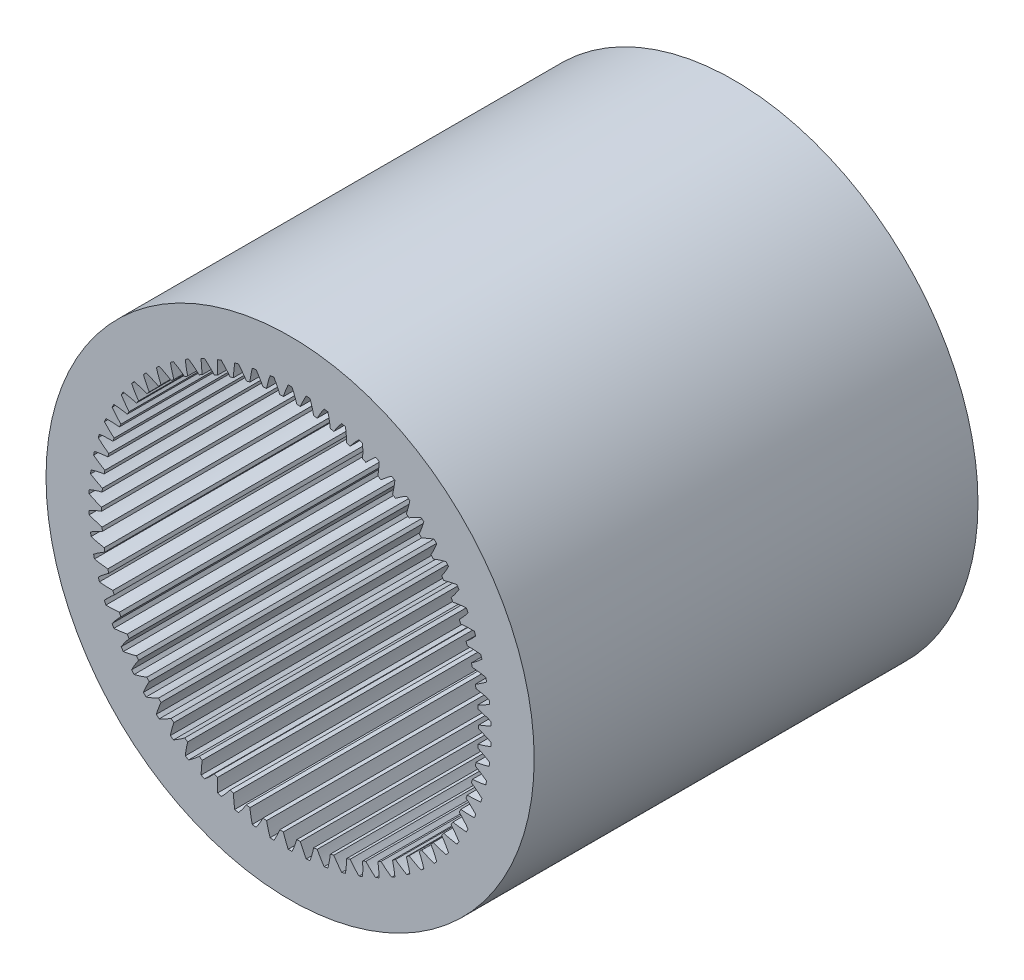
from build123d import *

# Parameters (mm, degrees)
SKETCH1_R           = 11
BOSS_EXTRUDE1_DEPTH = 20


with BuildPart() as part:
    # Sketch1 → Boss-Extrude1 (new body)
    with BuildSketch(Plane.XY):
        Circle(SKETCH1_R)
        with BuildLine():
            ThreePointArc((-8.348650628, -1.596882177), (-8.607630644, -1.756276652), (-8.854912419, -1.933276571))
            ThreePointArc((-8.854912419, -1.933276571), (-8.836259132, -2.016818485), (-8.816817685, -2.100180506))
            ThreePointArc((-8.816817685, -2.100180506), (-8.517227118, -2.152360382), (-8.214735515, -2.183602624))
            ThreePointArc((-8.214735515, -2.183602624), (-8.193684316, -2.261313187), (-8.171898, -2.338820872))
            ThreePointArc((-8.171898, -2.338820872), (-8.415547429, -2.520788461), (-8.645967569, -2.719241998))
            ThreePointArc((-8.645967569, -2.719241998), (-8.619900735, -2.800775529), (-8.59306504, -2.882059241))
            ThreePointArc((-8.59306504, -2.882059241), (-8.290003168, -2.907173964), (-7.985928775, -2.911175296))
            ThreePointArc((-7.985928775, -2.911175296), (-7.9579964, -2.986686005), (-7.929350055, -3.061928756))
            ThreePointArc((-7.929350055, -3.061928756), (-8.155707173, -3.265004363), (-8.367410472, -3.483313687))
            ThreePointArc((-8.367410472, -3.483313687), (-8.334139967, -3.562182374), (-8.300126088, -3.640733329))
            ThreePointArc((-8.300126088, -3.640733329), (-7.996032988, -3.638580692), (-7.692824032, -3.615308896))
            ThreePointArc((-7.692824032, -3.615308896), (-7.658235377, -3.688011782), (-7.622959645, -3.76038379))
            ThreePointArc((-7.622959645, -3.76038379), (-7.830201959, -3.98293237), (-8.021483906, -4.219339782))
            ThreePointArc((-8.021483906, -4.219339782), (-7.981277603, -4.294908622), (-7.940359401, -4.370094374))
            ThreePointArc((-7.940359401, -4.370094374), (-7.637683451, -4.340691706), (-7.337781193, -4.290334155))
            ThreePointArc((-7.337781193, -4.290334155), (-7.296814746, -4.359643858), (-7.255193647, -4.428562424))
            ThreePointArc((-7.255193647, -4.428562424), (-7.441652563, -4.668792148), (-7.610973068, -4.921394234))
            ThreePointArc((-7.610973068, -4.921394234), (-7.564154685, -4.993054791), (-7.516661609, -5.064269988))
            ThreePointArc((-7.516661609, -5.064269988), (-7.217839778, -5.007854024), (-6.923658854, -4.930816166))
            ThreePointArc((-6.923658854, -4.930816166), (-6.876644452, -4.996174644), (-6.829013095, -5.061084879))
            ThreePointArc((-6.829013095, -5.061084879), (-6.993187356, -5.317061556), (-7.13918315, -5.583824514))
            ThreePointArc((-7.13918315, -5.583824514), (-7.086129641, -5.650999819), (-7.032444077, -5.717671077))
            ThreePointArc((-7.032444077, -5.717671077), (-6.739882304, -5.634696045), (-6.453791286, -5.531598145))
            ThreePointArc((-6.453791286, -5.531598145), (-6.401107461, -5.59247917), (-6.347849345, -5.652858453))
            ThreePointArc((-6.347849345, -5.652858453), (-6.488417117, -5.922521111), (-6.609912727, -6.201297121))
            ThreePointArc((-6.609912727, -6.201297121), (-6.551051248, -6.263446319), (-6.491605441, -6.325036842))
            ThreePointArc((-6.491605441, -6.325036842), (-6.207659259, -6.216170808), (-5.931961585, -6.087842948))
            ThreePointArc((-5.931961585, -6.087842948), (-5.874032516, -6.143756343), (-5.815576445, -6.199118535))
            ThreePointArc((-5.815576445, -6.199118535), (-5.931405958, -6.480296008), (-6.027423174, -6.768840531))
            ThreePointArc((-6.027423174, -6.768840531), (-5.963227643, -6.825463232), (-5.898500215, -6.881477128))
            ThreePointArc((-5.898500215, -6.881477128), (-5.625455793, -6.747596617), (-5.362371217, -6.595072019))
            ThreePointArc((-5.362371217, -6.595072019), (-5.299663316, -6.645567601), (-5.236479943, -6.69546696))
            ThreePointArc((-5.236479943, -6.69546696), (-5.326638605, -6.985895373), (-5.396404353, -7.281885217))
            ThreePointArc((-5.396404353, -7.281885217), (-5.327391634, -7.332525529), (-5.257903733, -7.382511807))
            ThreePointArc((-5.257903733, -7.382511807), (-4.997959464, -7.224694747), (-4.749606189, -7.049201448))
            ThreePointArc((-4.749606189, -7.049201448), (-4.682624342, -7.093872657), (-4.615222383, -7.137907422))
            ThreePointArc((-4.615222383, -7.137907422), (-4.678984291, -7.435248415), (-4.721936857, -7.736300445))
            ThreePointArc((-4.721936857, -7.736300445), (-4.648662601, -7.780550641), (-4.574973702, -7.824106842))
            ThreePointArc((-4.574973702, -7.824106842), (-4.330222505, -7.643623882), (-4.098600125, -7.446574851))
            ThreePointArc((-4.098600125, -7.446574851), (-4.027883631, -7.485062021), (-3.956805766, -7.52287765))
            ThreePointArc((-3.956805766, -7.52287765), (-3.993657546, -7.824737209), (-4.009451102, -8.12842753))
            ThreePointArc((-4.009451102, -8.12842753), (-3.932505269, -8.165931334), (-3.855208673, -8.202706769))
            ThreePointArc((-3.855208673, -8.202706769), (-3.62762114, -8.001011052), (-3.414594542, -7.783992813))
            ThreePointArc((-3.414594542, -7.783992813), (-3.340712769, -7.815986067), (-3.266531276, -7.84727809))
            ThreePointArc((-3.266531276, -7.84727809), (-3.276176219, -8.15122582), (-3.264683604, -8.455109296))
            ThreePointArc((-3.264683604, -8.455109296), (-3.184685718, -8.48556475), (-3.10440377, -8.515263324))
            ThreePointArc((-3.10440377, -8.515263324), (-2.895812302, -8.293978786), (-2.703096652, -8.058738641))
            ThreePointArc((-2.703096652, -8.058738641), (-2.626644452, -8.083980389), (-2.549956596, -8.108496862))
            ThreePointArc((-2.549956596, -8.108496862), (-2.532317048, -8.412085553), (-2.493630794, -8.713715494))
            ThreePointArc((-2.493630794, -8.713715494), (-2.41122495, -8.736877388), (-2.328604034, -8.759259986))
            ThreePointArc((-2.328604034, -8.759259986), (-2.140688087, -8.520168279), (-1.969835017, -8.268600245))
            ThreePointArc((-1.969835017, -8.268600245), (-1.891427939, -8.286887254), (-1.812851166, -8.304430784))
            ThreePointArc((-1.812851166, -8.304430784), (-1.768069149, -8.60521612), (-1.702500735, -8.902163978))
            ThreePointArc((-1.702500735, -8.902163978), (-1.618350416, -8.917845826), (-1.534055747, -8.932732237))
            ThreePointArc((-1.534055747, -8.932732237), (-1.36832831, -8.677758387), (-1.220713429, -8.411887941))
            ThreePointArc((-1.220713429, -8.411887941), (-1.140982759, -8.423072975), (-1.061149724, -8.433502313))
            ThreePointArc((-1.061149724, -8.433502313), (-0.989585796, -8.729062547), (-0.89766314, -9.018937473))
            ThreePointArc((-0.89766314, -9.018937473), (-0.812445876, -9.027013014), (-0.727156145, -9.03428338))
            ThreePointArc((-0.727156145, -9.03428338), (-0.584951558, -8.765480287), (-0.461763374, -8.487448061))
            ThreePointArc((-0.461763374, -8.487448061), (-0.381351058, -8.491441066), (-0.300904528, -8.49467224))
            ThreePointArc((-0.300904528, -8.49467224), (-0.20313488, -8.782627694), (-0.08559809, -9.063095785))
            ThreePointArc((-0.08559809, -9.063095785), (0, -9.0635), (0.08559809, -9.063095785))
            ThreePointArc((0.08559809, -9.063095785), (0.20313488, -8.782627694), (0.300904528, -8.49467224))
            ThreePointArc((0.300904528, -8.49467224), (0.381351058, -8.491441066), (0.461763374, -8.487448061))
            ThreePointArc((0.461763374, -8.487448061), (0.584951558, -8.765480287), (0.727156145, -9.03428338))
            ThreePointArc((0.727156145, -9.03428338), (0.812445876, -9.027013014), (0.89766314, -9.018937473))
            ThreePointArc((0.89766314, -9.018937473), (0.989585796, -8.729062547), (1.061149724, -8.433502313))
            ThreePointArc((1.061149724, -8.433502313), (1.140982759, -8.423072975), (1.220713429, -8.411887941))
            ThreePointArc((1.220713429, -8.411887941), (1.36832831, -8.677758387), (1.534055747, -8.932732237))
            ThreePointArc((1.534055747, -8.932732237), (1.618350416, -8.917845826), (1.702500735, -8.902163978))
            ThreePointArc((1.702500735, -8.902163978), (1.768069149, -8.60521612), (1.812851166, -8.304430784))
            ThreePointArc((1.812851166, -8.304430784), (1.891427939, -8.286887254), (1.969835017, -8.268600245))
            ThreePointArc((1.969835017, -8.268600245), (2.140688087, -8.520168279), (2.328604034, -8.759259986))
            ThreePointArc((2.328604034, -8.759259986), (2.41122495, -8.736877388), (2.493630794, -8.713715494))
            ThreePointArc((2.493630794, -8.713715494), (2.532317048, -8.412085553), (2.549956596, -8.108496862))
            ThreePointArc((2.549956596, -8.108496862), (2.626644452, -8.083980389), (2.703096652, -8.058738641))
            ThreePointArc((2.703096652, -8.058738641), (2.895812302, -8.293978786), (3.10440377, -8.515263324))
            ThreePointArc((3.10440377, -8.515263324), (3.184685718, -8.48556475), (3.264683604, -8.455109296))
            ThreePointArc((3.264683604, -8.455109296), (3.276176219, -8.15122582), (3.266531276, -7.84727809))
            ThreePointArc((3.266531276, -7.84727809), (3.340712769, -7.815986067), (3.414594542, -7.783992813))
            ThreePointArc((3.414594542, -7.783992813), (3.62762114, -8.001011052), (3.855208673, -8.202706769))
            ThreePointArc((3.855208673, -8.202706769), (3.932505269, -8.165931334), (4.009451102, -8.12842753))
            ThreePointArc((4.009451102, -8.12842753), (3.993657546, -7.824737209), (3.956805766, -7.52287765))
            ThreePointArc((3.956805766, -7.52287765), (4.027883631, -7.485062021), (4.098600125, -7.446574851))
            ThreePointArc((4.098600125, -7.446574851), (4.330222505, -7.643623882), (4.574973702, -7.824106842))
            ThreePointArc((4.574973702, -7.824106842), (4.648662601, -7.780550641), (4.721936857, -7.736300445))
            ThreePointArc((4.721936857, -7.736300445), (4.678984291, -7.435248415), (4.615222383, -7.137907422))
            ThreePointArc((4.615222383, -7.137907422), (4.682624342, -7.093872657), (4.749606189, -7.049201448))
            ThreePointArc((4.749606189, -7.049201448), (4.997959464, -7.224694747), (5.257903733, -7.382511807))
            ThreePointArc((5.257903733, -7.382511807), (5.327391634, -7.332525529), (5.396404353, -7.281885217))
            ThreePointArc((5.396404353, -7.281885217), (5.326638605, -6.985895373), (5.236479943, -6.69546696))
            ThreePointArc((5.236479943, -6.69546696), (5.299663316, -6.645567601), (5.362371217, -6.595072019))
            ThreePointArc((5.362371217, -6.595072019), (5.625455793, -6.747596617), (5.898500215, -6.881477128))
            ThreePointArc((5.898500215, -6.881477128), (5.963227643, -6.825463232), (6.027423174, -6.768840531))
            ThreePointArc((6.027423174, -6.768840531), (5.931405958, -6.480296008), (5.815576445, -6.199118535))
            ThreePointArc((5.815576445, -6.199118535), (5.874032516, -6.143756343), (5.931961585, -6.087842948))
            ThreePointArc((5.931961585, -6.087842948), (6.207659259, -6.216170808), (6.491605441, -6.325036842))
            ThreePointArc((6.491605441, -6.325036842), (6.551051248, -6.263446319), (6.609912727, -6.201297121))
            ThreePointArc((6.609912727, -6.201297121), (6.488417117, -5.922521111), (6.347849345, -5.652858453))
            ThreePointArc((6.347849345, -5.652858453), (6.401107461, -5.59247917), (6.453791286, -5.531598145))
            ThreePointArc((6.453791286, -5.531598145), (6.739882304, -5.634696045), (7.032444077, -5.717671077))
            ThreePointArc((7.032444077, -5.717671077), (7.086129641, -5.650999819), (7.13918315, -5.583824514))
            ThreePointArc((7.13918315, -5.583824514), (6.993187356, -5.317061556), (6.829013095, -5.061084879))
            ThreePointArc((6.829013095, -5.061084879), (6.876644452, -4.996174644), (6.923658854, -4.930816166))
            ThreePointArc((6.923658854, -4.930816166), (7.217839778, -5.007854024), (7.516661609, -5.064269988))
            ThreePointArc((7.516661609, -5.064269988), (7.564154685, -4.993054791), (7.610973068, -4.921394234))
            ThreePointArc((7.610973068, -4.921394234), (7.441652563, -4.668792148), (7.255193647, -4.428562424))
            ThreePointArc((7.255193647, -4.428562424), (7.296814746, -4.359643858), (7.337781193, -4.290334155))
            ThreePointArc((7.337781193, -4.290334155), (7.637683451, -4.340691706), (7.940359401, -4.370094374))
            ThreePointArc((7.940359401, -4.370094374), (7.981277603, -4.294908622), (8.021483906, -4.219339782))
            ThreePointArc((8.021483906, -4.219339782), (7.830201959, -3.98293237), (7.622959645, -3.76038379))
            ThreePointArc((7.622959645, -3.76038379), (7.658235377, -3.688011782), (7.692824032, -3.615308896))
            ThreePointArc((7.692824032, -3.615308896), (7.996032988, -3.638580692), (8.300126088, -3.640733329))
            ThreePointArc((8.300126088, -3.640733329), (8.334139967, -3.562182374), (8.367410472, -3.483313687))
            ThreePointArc((8.367410472, -3.483313687), (8.155707173, -3.265004363), (7.929350055, -3.061928756))
            ThreePointArc((7.929350055, -3.061928756), (7.9579964, -2.986686005), (7.985928775, -2.911175296))
            ThreePointArc((7.985928775, -2.911175296), (8.290003168, -2.907173964), (8.59306504, -2.882059241))
            ThreePointArc((8.59306504, -2.882059241), (8.619900735, -2.800775529), (8.645967569, -2.719241998))
            ThreePointArc((8.645967569, -2.719241998), (8.415547429, -2.520788461), (8.171898, -2.338820872))
            ThreePointArc((8.171898, -2.338820872), (8.193684316, -2.261313187), (8.214735515, -2.183602624))
            ThreePointArc((8.214735515, -2.183602624), (8.517227118, -2.152360382), (8.816817685, -2.100180506))
            ThreePointArc((8.816817685, -2.100180506), (8.836259132, -2.016818485), (8.854912419, -1.933276571))
            ThreePointArc((8.854912419, -1.933276571), (8.607630644, -1.756276652), (8.348650628, -1.596882177))
            ThreePointArc((8.348650628, -1.596882177), (8.363401503, -1.517733606), (8.377402035, -1.438448867))
            ThreePointArc((8.377402035, -1.438448867), (8.675875363, -1.380217259), (8.969582498, -1.301392353))
            ThreePointArc((8.969582498, -1.301392353), (8.981473166, -1.216623205), (8.992562721, -1.131745538))
            ThreePointArc((8.992562721, -1.131745538), (8.730410279, -0.977624336), (8.45818483, -0.842086327))
            ThreePointArc((8.45818483, -0.842086327), (8.465781499, -0.761934126), (8.47261864, -0.681713566))
            ThreePointArc((8.47261864, -0.681713566), (8.76467056, -0.596961439), (9.050129507, -0.492126154))
            ThreePointArc((9.050129507, -0.492126154), (9.054373659, -0.40663239), (9.057810195, -0.321102356))
            ThreePointArc((9.057810195, -0.321102356), (8.782897784, -0.191100764), (8.499618701, -0.080510492))
            ThreePointArc((8.499618701, -0.080510492), (8.5, 0), (8.499618701, 0.080510492))
            ThreePointArc((8.499618701, 0.080510492), (8.782897784, 0.191100764), (9.057810195, 0.321102356))
            ThreePointArc((9.057810195, 0.321102356), (9.054373659, 0.40663239), (9.050129507, 0.492126154))
            ThreePointArc((9.050129507, 0.492126154), (8.76467056, 0.596961439), (8.47261864, 0.681713566))
            ThreePointArc((8.47261864, 0.681713566), (8.465781499, 0.761934126), (8.45818483, 0.842086327))
            ThreePointArc((8.45818483, 0.842086327), (8.730410279, 0.977624336), (8.992562721, 1.131745538))
            ThreePointArc((8.992562721, 1.131745538), (8.981473166, 1.216623205), (8.969582498, 1.301392353))
            ThreePointArc((8.969582498, 1.301392353), (8.675875363, 1.380217259), (8.377402035, 1.438448867))
            ThreePointArc((8.377402035, 1.438448867), (8.363401503, 1.517733606), (8.348650628, 1.596882177))
            ThreePointArc((8.348650628, 1.596882177), (8.607630644, 1.756276652), (8.854912419, 1.933276571))
            ThreePointArc((8.854912419, 1.933276571), (8.836259132, 2.016818485), (8.816817685, 2.100180506))
            ThreePointArc((8.816817685, 2.100180506), (8.517227118, 2.152360382), (8.214735515, 2.183602624))
            ThreePointArc((8.214735515, 2.183602624), (8.193684316, 2.261313187), (8.171898, 2.338820872))
            ThreePointArc((8.171898, 2.338820872), (8.415547429, 2.520788461), (8.645967569, 2.719241998))
            ThreePointArc((8.645967569, 2.719241998), (8.619900735, 2.800775529), (8.59306504, 2.882059241))
            ThreePointArc((8.59306504, 2.882059241), (8.290003168, 2.907173964), (7.985928775, 2.911175296))
            ThreePointArc((7.985928775, 2.911175296), (7.9579964, 2.986686005), (7.929350055, 3.061928756))
            ThreePointArc((7.929350055, 3.061928756), (8.155707173, 3.265004363), (8.367410472, 3.483313687))
            ThreePointArc((8.367410472, 3.483313687), (8.334139967, 3.562182374), (8.300126088, 3.640733329))
            ThreePointArc((8.300126088, 3.640733329), (7.996032988, 3.638580692), (7.692824032, 3.615308896))
            ThreePointArc((7.692824032, 3.615308896), (7.658235377, 3.688011782), (7.622959645, 3.76038379))
            ThreePointArc((7.622959645, 3.76038379), (7.830201959, 3.98293237), (8.021483906, 4.219339782))
            ThreePointArc((8.021483906, 4.219339782), (7.981277603, 4.294908622), (7.940359401, 4.370094374))
            ThreePointArc((7.940359401, 4.370094374), (7.637683451, 4.340691706), (7.337781193, 4.290334155))
            ThreePointArc((7.337781193, 4.290334155), (7.296814746, 4.359643858), (7.255193647, 4.428562424))
            ThreePointArc((7.255193647, 4.428562424), (7.441652563, 4.668792148), (7.610973068, 4.921394234))
            ThreePointArc((7.610973068, 4.921394234), (7.564154685, 4.993054791), (7.516661609, 5.064269988))
            ThreePointArc((7.516661609, 5.064269988), (7.217839778, 5.007854024), (6.923658854, 4.930816166))
            ThreePointArc((6.923658854, 4.930816166), (6.876644452, 4.996174644), (6.829013095, 5.061084879))
            ThreePointArc((6.829013095, 5.061084879), (6.993187356, 5.317061556), (7.13918315, 5.583824514))
            ThreePointArc((7.13918315, 5.583824514), (7.086129641, 5.650999819), (7.032444077, 5.717671077))
            ThreePointArc((7.032444077, 5.717671077), (6.739882304, 5.634696045), (6.453791286, 5.531598145))
            ThreePointArc((6.453791286, 5.531598145), (6.401107461, 5.59247917), (6.347849345, 5.652858453))
            ThreePointArc((6.347849345, 5.652858453), (6.488417117, 5.922521111), (6.609912727, 6.201297121))
            ThreePointArc((6.609912727, 6.201297121), (6.551051248, 6.263446319), (6.491605441, 6.325036842))
            ThreePointArc((6.491605441, 6.325036842), (6.207659259, 6.216170808), (5.931961585, 6.087842948))
            ThreePointArc((5.931961585, 6.087842948), (5.874032516, 6.143756343), (5.815576445, 6.199118535))
            ThreePointArc((5.815576445, 6.199118535), (5.931405958, 6.480296008), (6.027423174, 6.768840531))
            ThreePointArc((6.027423174, 6.768840531), (5.963227643, 6.825463232), (5.898500215, 6.881477128))
            ThreePointArc((5.898500215, 6.881477128), (5.625455793, 6.747596617), (5.362371217, 6.595072019))
            ThreePointArc((5.362371217, 6.595072019), (5.299663316, 6.645567601), (5.236479943, 6.69546696))
            ThreePointArc((5.236479943, 6.69546696), (5.326638605, 6.985895373), (5.396404353, 7.281885217))
            ThreePointArc((5.396404353, 7.281885217), (5.327391634, 7.332525529), (5.257903733, 7.382511807))
            ThreePointArc((5.257903733, 7.382511807), (4.997959464, 7.224694747), (4.749606189, 7.049201448))
            ThreePointArc((4.749606189, 7.049201448), (4.682624342, 7.093872657), (4.615222383, 7.137907422))
            ThreePointArc((4.615222383, 7.137907422), (4.678984291, 7.435248415), (4.721936857, 7.736300445))
            ThreePointArc((4.721936857, 7.736300445), (4.648662601, 7.780550641), (4.574973702, 7.824106842))
            ThreePointArc((4.574973702, 7.824106842), (4.330222505, 7.643623882), (4.098600125, 7.446574851))
            ThreePointArc((4.098600125, 7.446574851), (4.027883631, 7.485062021), (3.956805766, 7.52287765))
            ThreePointArc((3.956805766, 7.52287765), (3.993657546, 7.824737209), (4.009451102, 8.12842753))
            ThreePointArc((4.009451102, 8.12842753), (3.932505269, 8.165931334), (3.855208673, 8.202706769))
            ThreePointArc((3.855208673, 8.202706769), (3.62762114, 8.001011052), (3.414594542, 7.783992813))
            ThreePointArc((3.414594542, 7.783992813), (3.340712769, 7.815986067), (3.266531276, 7.84727809))
            ThreePointArc((3.266531276, 7.84727809), (3.276176219, 8.15122582), (3.264683604, 8.455109296))
            ThreePointArc((3.264683604, 8.455109296), (3.184685718, 8.48556475), (3.10440377, 8.515263324))
            ThreePointArc((3.10440377, 8.515263324), (2.895812302, 8.293978786), (2.703096652, 8.058738641))
            ThreePointArc((2.703096652, 8.058738641), (2.626644452, 8.083980389), (2.549956596, 8.108496862))
            ThreePointArc((2.549956596, 8.108496862), (2.532317048, 8.412085553), (2.493630794, 8.713715494))
            ThreePointArc((2.493630794, 8.713715494), (2.41122495, 8.736877388), (2.328604034, 8.759259986))
            ThreePointArc((2.328604034, 8.759259986), (2.140688087, 8.520168279), (1.969835017, 8.268600245))
            ThreePointArc((1.969835017, 8.268600245), (1.891427939, 8.286887254), (1.812851166, 8.304430784))
            ThreePointArc((1.812851166, 8.304430784), (1.768069149, 8.60521612), (1.702500735, 8.902163978))
            ThreePointArc((1.702500735, 8.902163978), (1.618350416, 8.917845826), (1.534055747, 8.932732237))
            ThreePointArc((1.534055747, 8.932732237), (1.36832831, 8.677758387), (1.220713429, 8.411887941))
            ThreePointArc((1.220713429, 8.411887941), (1.140982759, 8.423072975), (1.061149724, 8.433502313))
            ThreePointArc((1.061149724, 8.433502313), (0.989585796, 8.729062547), (0.89766314, 9.018937473))
            ThreePointArc((0.89766314, 9.018937473), (0.812445876, 9.027013014), (0.727156145, 9.03428338))
            ThreePointArc((0.727156145, 9.03428338), (0.584951558, 8.765480287), (0.461763374, 8.487448061))
            ThreePointArc((0.461763374, 8.487448061), (0.381351058, 8.491441066), (0.300904528, 8.49467224))
            ThreePointArc((0.300904528, 8.49467224), (0.20313488, 8.782627694), (0.08559809, 9.063095785))
            ThreePointArc((0.08559809, 9.063095785), (0, 9.0635), (-0.08559809, 9.063095785))
            ThreePointArc((-0.08559809, 9.063095785), (-0.20313488, 8.782627694), (-0.300904528, 8.49467224))
            ThreePointArc((-0.300904528, 8.49467224), (-0.381351058, 8.491441066), (-0.461763374, 8.487448061))
            ThreePointArc((-0.461763374, 8.487448061), (-0.584951558, 8.765480287), (-0.727156145, 9.03428338))
            ThreePointArc((-0.727156145, 9.03428338), (-0.812445876, 9.027013014), (-0.89766314, 9.018937473))
            ThreePointArc((-0.89766314, 9.018937473), (-0.989585796, 8.729062547), (-1.061149724, 8.433502313))
            ThreePointArc((-1.061149724, 8.433502313), (-1.140982759, 8.423072975), (-1.220713429, 8.411887941))
            ThreePointArc((-1.220713429, 8.411887941), (-1.36832831, 8.677758387), (-1.534055747, 8.932732237))
            ThreePointArc((-1.534055747, 8.932732237), (-1.618350416, 8.917845826), (-1.702500735, 8.902163978))
            ThreePointArc((-1.702500735, 8.902163978), (-1.768069149, 8.60521612), (-1.812851166, 8.304430784))
            ThreePointArc((-1.812851166, 8.304430784), (-1.891427939, 8.286887254), (-1.969835017, 8.268600245))
            ThreePointArc((-1.969835017, 8.268600245), (-2.140688087, 8.520168279), (-2.328604034, 8.759259986))
            ThreePointArc((-2.328604034, 8.759259986), (-2.41122495, 8.736877388), (-2.493630794, 8.713715494))
            ThreePointArc((-2.493630794, 8.713715494), (-2.532317048, 8.412085553), (-2.549956596, 8.108496862))
            ThreePointArc((-2.549956596, 8.108496862), (-2.626644452, 8.083980389), (-2.703096652, 8.058738641))
            ThreePointArc((-2.703096652, 8.058738641), (-2.895812302, 8.293978786), (-3.10440377, 8.515263324))
            ThreePointArc((-3.10440377, 8.515263324), (-3.184685718, 8.48556475), (-3.264683604, 8.455109296))
            ThreePointArc((-3.264683604, 8.455109296), (-3.276176219, 8.15122582), (-3.266531276, 7.84727809))
            ThreePointArc((-3.266531276, 7.84727809), (-3.340712769, 7.815986067), (-3.414594542, 7.783992813))
            ThreePointArc((-3.414594542, 7.783992813), (-3.62762114, 8.001011052), (-3.855208673, 8.202706769))
            ThreePointArc((-3.855208673, 8.202706769), (-3.932505269, 8.165931334), (-4.009451102, 8.12842753))
            ThreePointArc((-4.009451102, 8.12842753), (-3.993657546, 7.824737209), (-3.956805766, 7.52287765))
            ThreePointArc((-3.956805766, 7.52287765), (-4.027883631, 7.485062021), (-4.098600125, 7.446574851))
            ThreePointArc((-4.098600125, 7.446574851), (-4.330222505, 7.643623882), (-4.574973702, 7.824106842))
            ThreePointArc((-4.574973702, 7.824106842), (-4.648662601, 7.780550641), (-4.721936857, 7.736300445))
            ThreePointArc((-4.721936857, 7.736300445), (-4.678984291, 7.435248415), (-4.615222383, 7.137907422))
            ThreePointArc((-4.615222383, 7.137907422), (-4.682624342, 7.093872657), (-4.749606189, 7.049201448))
            ThreePointArc((-4.749606189, 7.049201448), (-4.997959464, 7.224694747), (-5.257903733, 7.382511807))
            ThreePointArc((-5.257903733, 7.382511807), (-5.327391634, 7.332525529), (-5.396404353, 7.281885217))
            ThreePointArc((-5.396404353, 7.281885217), (-5.326638605, 6.985895373), (-5.236479943, 6.69546696))
            ThreePointArc((-5.236479943, 6.69546696), (-5.299663316, 6.645567601), (-5.362371217, 6.595072019))
            ThreePointArc((-5.362371217, 6.595072019), (-5.625455793, 6.747596617), (-5.898500215, 6.881477128))
            ThreePointArc((-5.898500215, 6.881477128), (-5.963227643, 6.825463232), (-6.027423174, 6.768840531))
            ThreePointArc((-6.027423174, 6.768840531), (-5.931405958, 6.480296008), (-5.815576445, 6.199118535))
            ThreePointArc((-5.815576445, 6.199118535), (-5.874032516, 6.143756343), (-5.931961585, 6.087842948))
            ThreePointArc((-5.931961585, 6.087842948), (-6.207659259, 6.216170808), (-6.491605441, 6.325036842))
            ThreePointArc((-6.491605441, 6.325036842), (-6.551051248, 6.263446319), (-6.609912727, 6.201297121))
            ThreePointArc((-6.609912727, 6.201297121), (-6.488417117, 5.922521111), (-6.347849345, 5.652858453))
            ThreePointArc((-6.347849345, 5.652858453), (-6.401107461, 5.59247917), (-6.453791286, 5.531598145))
            ThreePointArc((-6.453791286, 5.531598145), (-6.739882304, 5.634696045), (-7.032444077, 5.717671077))
            ThreePointArc((-7.032444077, 5.717671077), (-7.086129641, 5.650999819), (-7.13918315, 5.583824514))
            ThreePointArc((-7.13918315, 5.583824514), (-6.993187356, 5.317061556), (-6.829013095, 5.061084879))
            ThreePointArc((-6.829013095, 5.061084879), (-6.876644452, 4.996174644), (-6.923658854, 4.930816166))
            ThreePointArc((-6.923658854, 4.930816166), (-7.217839778, 5.007854024), (-7.516661609, 5.064269988))
            ThreePointArc((-7.516661609, 5.064269988), (-7.564154685, 4.993054791), (-7.610973068, 4.921394234))
            ThreePointArc((-7.610973068, 4.921394234), (-7.441652563, 4.668792148), (-7.255193647, 4.428562424))
            ThreePointArc((-7.255193647, 4.428562424), (-7.296814746, 4.359643858), (-7.337781193, 4.290334155))
            ThreePointArc((-7.337781193, 4.290334155), (-7.637683451, 4.340691706), (-7.940359401, 4.370094374))
            ThreePointArc((-7.940359401, 4.370094374), (-7.981277603, 4.294908622), (-8.021483906, 4.219339782))
            ThreePointArc((-8.021483906, 4.219339782), (-7.830201959, 3.98293237), (-7.622959645, 3.76038379))
            ThreePointArc((-7.622959645, 3.76038379), (-7.658235377, 3.688011782), (-7.692824032, 3.615308896))
            ThreePointArc((-7.692824032, 3.615308896), (-7.996032988, 3.638580692), (-8.300126088, 3.640733329))
            ThreePointArc((-8.300126088, 3.640733329), (-8.334139967, 3.562182374), (-8.367410472, 3.483313687))
            ThreePointArc((-8.367410472, 3.483313687), (-8.155707173, 3.265004363), (-7.929350055, 3.061928756))
            ThreePointArc((-7.929350055, 3.061928756), (-7.9579964, 2.986686005), (-7.985928775, 2.911175296))
            ThreePointArc((-7.985928775, 2.911175296), (-8.290003168, 2.907173964), (-8.59306504, 2.882059241))
            ThreePointArc((-8.59306504, 2.882059241), (-8.619900735, 2.800775529), (-8.645967569, 2.719241998))
            ThreePointArc((-8.645967569, 2.719241998), (-8.415547429, 2.520788461), (-8.171898, 2.338820872))
            ThreePointArc((-8.171898, 2.338820872), (-8.193684316, 2.261313187), (-8.214735515, 2.183602624))
            ThreePointArc((-8.214735515, 2.183602624), (-8.517227118, 2.152360382), (-8.816817685, 2.100180506))
            ThreePointArc((-8.816817685, 2.100180506), (-8.836259132, 2.016818485), (-8.854912419, 1.933276571))
            ThreePointArc((-8.854912419, 1.933276571), (-8.607630644, 1.756276652), (-8.348650628, 1.596882177))
            ThreePointArc((-8.348650628, 1.596882177), (-8.363401503, 1.517733606), (-8.377402035, 1.438448867))
            ThreePointArc((-8.377402035, 1.438448867), (-8.675875363, 1.380217259), (-8.969582498, 1.301392353))
            ThreePointArc((-8.969582498, 1.301392353), (-8.981473166, 1.216623205), (-8.992562721, 1.131745538))
            ThreePointArc((-8.992562721, 1.131745538), (-8.730410279, 0.977624336), (-8.45818483, 0.842086327))
            ThreePointArc((-8.45818483, 0.842086327), (-8.465781499, 0.761934126), (-8.47261864, 0.681713566))
            ThreePointArc((-8.47261864, 0.681713566), (-8.76467056, 0.596961439), (-9.050129507, 0.492126154))
            ThreePointArc((-9.050129507, 0.492126154), (-9.054373659, 0.40663239), (-9.057810195, 0.321102356))
            ThreePointArc((-9.057810195, 0.321102356), (-8.782897784, 0.191100764), (-8.499618701, 0.080510492))
            ThreePointArc((-8.499618701, 0.080510492), (-8.5, 0), (-8.499618701, -0.080510492))
            ThreePointArc((-8.499618701, -0.080510492), (-8.782897784, -0.191100764), (-9.057810195, -0.321102356))
            ThreePointArc((-9.057810195, -0.321102356), (-9.054373659, -0.40663239), (-9.050129507, -0.492126154))
            ThreePointArc((-9.050129507, -0.492126154), (-8.76467056, -0.596961439), (-8.47261864, -0.681713566))
            ThreePointArc((-8.47261864, -0.681713566), (-8.465781499, -0.761934126), (-8.45818483, -0.842086327))
            ThreePointArc((-8.45818483, -0.842086327), (-8.730410279, -0.977624336), (-8.992562721, -1.131745538))
            ThreePointArc((-8.992562721, -1.131745538), (-8.981473166, -1.216623205), (-8.969582498, -1.301392353))
            ThreePointArc((-8.969582498, -1.301392353), (-8.675875363, -1.380217259), (-8.377402035, -1.438448867))
            ThreePointArc((-8.377402035, -1.438448867), (-8.363401503, -1.517733606), (-8.348650628, -1.596882177))
        make_face(mode=Mode.SUBTRACT)
    extrude(amount=BOSS_EXTRUDE1_DEPTH)


solid = part.part
